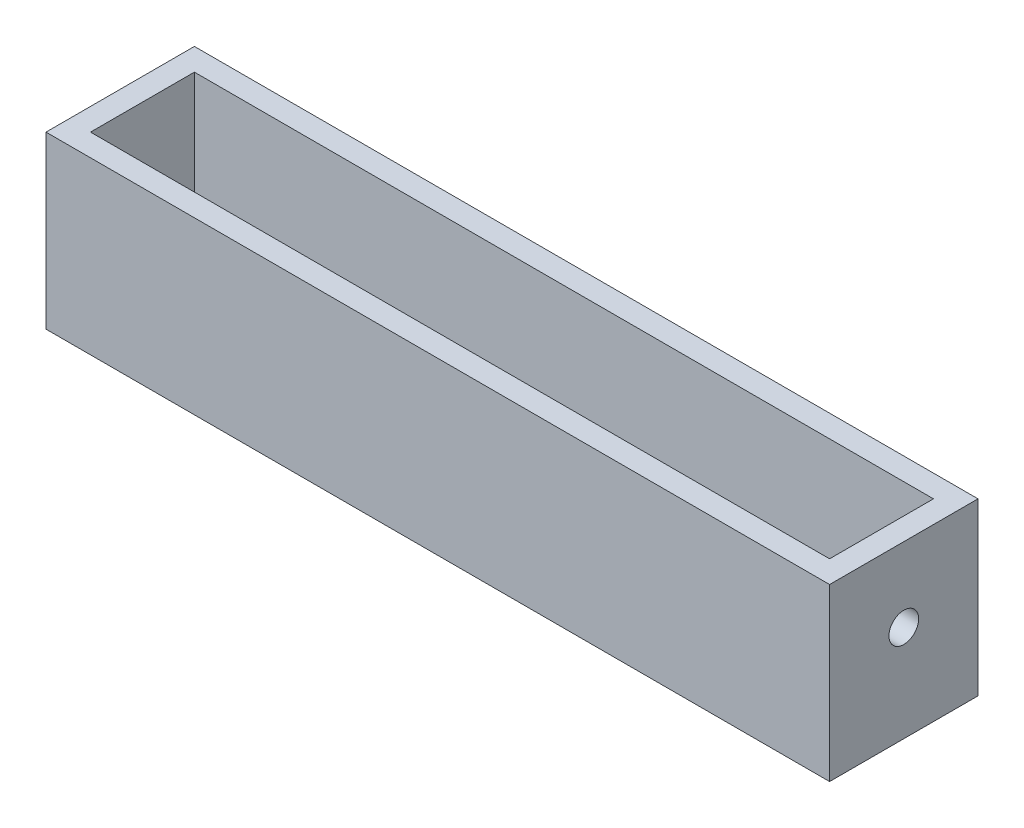
from build123d import *

# Parameters (mm, degrees)
SKETCH_1_W          = 105.6
SKETCH_1_H          = 20
SKETCH_1_R          = 4
EXTRUDE_1_DEPTH     = 3
SKETCH_10_W         = 105.6
SKETCH_10_H         = 20
SKETCH_10_W_2       = 99.6
SKETCH_10_H_2       = 14
EXTRUDE_2_DEPTH     = 20
SKETCH_11_R         = 2
CUT_EXTRUDE_1_DEPTH = 110


with BuildPart() as part:
    # 草图1 → 凸台-拉伸1 (new body)
    with BuildSketch(Plane(origin=(0, 0, 0), x_dir=(1, 0, 0), z_dir=(0, 1, 0))):
        Rectangle(SKETCH_1_W, SKETCH_1_H)
        with Locations((-37.5, 0)):
            Circle(SKETCH_1_R, mode=Mode.SUBTRACT)
        with Locations((37.5, 0)):
            Circle(SKETCH_1_R, mode=Mode.SUBTRACT)
    extrude(amount=EXTRUDE_1_DEPTH)

    # 草图10 → 凸台-拉伸2 (add)
    with BuildSketch(Plane(origin=(0, 3, 0), x_dir=(1, 0, 0), z_dir=(0, 1, 0))):
        Rectangle(SKETCH_10_W, SKETCH_10_H)
        Rectangle(SKETCH_10_W_2, SKETCH_10_H_2, mode=Mode.SUBTRACT)
    extrude(amount=EXTRUDE_2_DEPTH)

    # 草图11 → 切除-拉伸1 (cut)
    with BuildSketch(Plane.ZY.offset(52.8)):
        with Locations((0, 13)):
            Circle(SKETCH_11_R)
    extrude(amount=-CUT_EXTRUDE_1_DEPTH, mode=Mode.SUBTRACT)


solid = part.part
